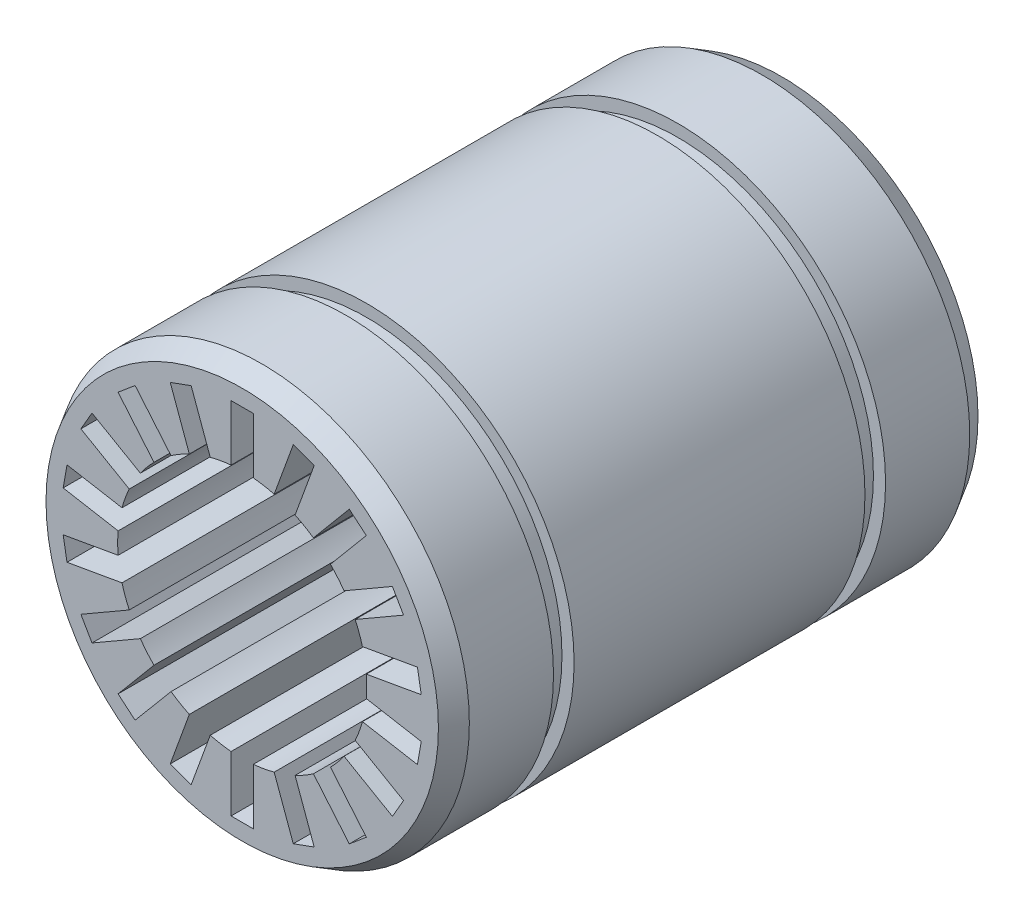
from build123d import *
from OCP.BRepFilletAPI import BRepFilletAPI_MakeChamfer

# Parameters (mm, degrees)
BORE_DEPTH          = 31.494879181
BORE_DEPTH_BACK     = 31.494879181
SKETCH2_R           = 9.525
SKETCH3_W           = 1.7018
SKETCH3_H           = 4.271416332
RIDGE_DEPTH         = 31.494879181
RIDGE_PATTERN_COUNT = 18
OD_CHAMFER_SIZE     = 1.5
OD_CHAMFER_SIZE2    = 0.866025404


with BuildPart() as part:
    # Sketch1 → Bearing (revolve)
    with BuildSketch(Plane(origin=(0, 0, 0), x_dir=(0, 0, -1), z_dir=(1, 0, 0))):
        Polygon((-20.6375, 0), (20.6375, 0), (20.6375, -15.875), (12.7, -15.875), (12.7, -14.9479), (11.1252, -14.9479), (11.1252, -15.875), (-11.1252, -15.875), (-11.1252, -14.9479), (-12.7, -14.9479), (-12.7, -15.875), (-20.6375, -15.875), align=None)
    revolve(axis=Axis((0, 0, 20.6375), (0, 0, -1)))

    # Sketch2 → Bore (cut, two sides: drawn at the far end of the back side and taken through both)
    with BuildSketch(Plane.XY.offset(-BORE_DEPTH_BACK)):
        Circle(SKETCH2_R)
    extrude(amount=BORE_DEPTH + BORE_DEPTH_BACK, mode=Mode.SUBTRACT)

    # Sketch3 → Ridge (cut, symmetric)
    with BuildSketch(Plane.XY):
        with Locations((0, 11.622625167)):
            Rectangle(SKETCH3_W, SKETCH3_H)
    ridge = extrude(amount=RIDGE_DEPTH, both=True, mode=Mode.SUBTRACT)

    # Ridge Pattern: Ridge ×18 about axis
    ridge_pattern_axis = Axis((0, 0, 20.6375), (0, 0, 1))
    for i in range(1, RIDGE_PATTERN_COUNT):
        add(ridge.rotate(ridge_pattern_axis, i * 360 / RIDGE_PATTERN_COUNT), mode=Mode.SUBTRACT)

    # OD Chamfer: one chamfer whose edges measure the first distance from different faces: ONE call of the kernel's chamfer builder (chamfer() names one face for all edges)
    od_chamfer_edges_1 = [part.edges().sort_by_distance(p)[0] for p in [
        (0, 15.875, -20.6375),
    ]]
    od_chamfer_side_1 = [part.faces().sort_by_distance(p)[0] for p in [
        (0, 15.875, -16.66875),
    ]]
    od_chamfer_edges_2 = [part.edges().sort_by_distance(p)[0] for p in [
        (0, 15.875, 20.6375),
    ]]
    od_chamfer_side_2 = [part.faces().sort_by_distance(p)[0] for p in [
        (0, 15.875, 16.66875),
    ]]
    od_chamfer = BRepFilletAPI_MakeChamfer(part.part.solid().wrapped)
    for e in od_chamfer_edges_1:
        od_chamfer.Add(OD_CHAMFER_SIZE, OD_CHAMFER_SIZE2, e.wrapped, od_chamfer_side_1[0].wrapped)  # the first distance lies on this face
    for e in od_chamfer_edges_2:
        od_chamfer.Add(OD_CHAMFER_SIZE, OD_CHAMFER_SIZE2, e.wrapped, od_chamfer_side_2[0].wrapped)  # the first distance lies on this face
    add(Compound.cast(od_chamfer.Shape()), mode=Mode.REPLACE)


solid = part.part
